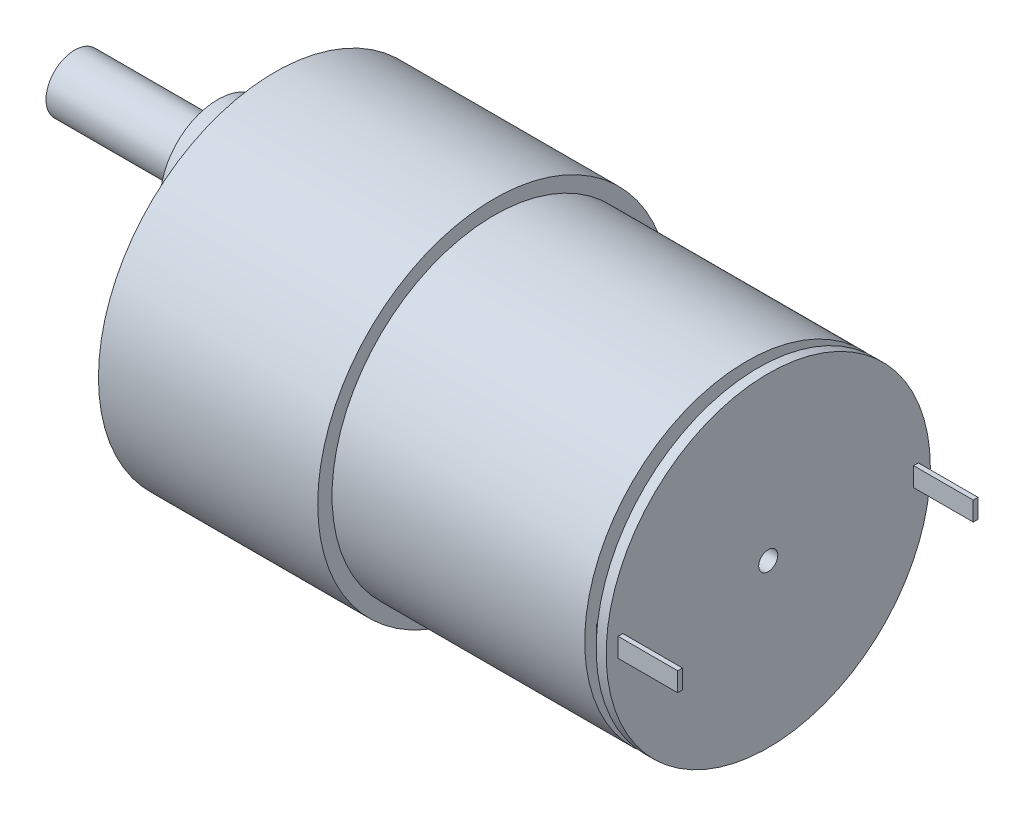
from build123d import *

# Parameters (mm, degrees)
SKETCH1_R                      = 17
BOSS_EXTRUDE1_DEPTH            = 1.05
SKETCH2_W                      = 0.5
SKETCH2_H                      = 2
POLES_DEPTH                    = 1.2
POLES_DEPTH_BACK               = 7.3
SKETCH3_R                      = 1.5
BOSS_EXTRUDE3_DEPTH            = 1.2
SKETCH5_R                      = 17
BOSS_EXTRUDE5_DEPTH            = 26.5
SKETCH6_R                      = 18.5
REDUCTUR_DEPTH                 = 21.5
SKETCH35_R                     = 18.5
ENDPLATE_DEPTH                 = 1.5
SKETCH36_R                     = 6
BOSS_EXTRUDE25_DEPTH           = 6
F_3_1_3_1_DIAMETER_HOLE1_D     = 6
F_3_1_3_1_DIAMETER_HOLE1_DEPTH = 2.2
F_2_0_2_DIAMETER_HOLE1_D       = 2
F_2_0_2_DIAMETER_HOLE1_DEPTH   = 2.25
F_3_0MM_1_D                    = 3
F_3_0MM_1_DEPTH                = 7.5
F_3_0MM_1_TIP                  = 0.901290929
SKETCH_1_R                     = 3
EXTRUDE_1_DEPTH                = 21


with BuildPart() as part:
    # Sketch1 → Boss-Extrude1 (new body)
    with BuildSketch(Plane(origin=(41.25, 0, 0), x_dir=(0, 0, -1), z_dir=(1, 0, 0))):
        Circle(SKETCH1_R)
    extrude(amount=-BOSS_EXTRUDE1_DEPTH)

    # Sketch2 → Poles (add, two sides)
    with BuildSketch(Plane.ZY.offset(-40.2)) as poles_sk:
        with Locations((15.5, 0)):
            Rectangle(SKETCH2_W, SKETCH2_H)
        with Locations((-15.5, 0)):
            Rectangle(SKETCH2_W, SKETCH2_H)
    extrude(amount=POLES_DEPTH)
    extrude(poles_sk.sketch, amount=-POLES_DEPTH_BACK)

    # Sketch3 → Boss-Extrude3 (add)
    with BuildSketch(Plane.ZY.offset(-40.2)):
        Circle(SKETCH3_R)
    extrude(amount=BOSS_EXTRUDE3_DEPTH)

    # Sketch5 → Boss-Extrude5 (add)
    with BuildSketch(Plane(origin=(39, 0, 0), x_dir=(0, 0, -1), z_dir=(1, 0, 0))):
        Circle(SKETCH5_R)
    extrude(amount=-BOSS_EXTRUDE5_DEPTH)

    # Sketch6 → Reductur (add)
    with BuildSketch(Plane(origin=(12.5, 0, 0), x_dir=(0, 0, -1), z_dir=(1, 0, 0))):
        Circle(SKETCH6_R)
    extrude(amount=-REDUCTUR_DEPTH)

    # Sketch35 → Endplate (add)
    with BuildSketch(Plane.ZY.offset(9)):
        Circle(SKETCH35_R)
    extrude(amount=ENDPLATE_DEPTH)

    # Sketch36 → Boss-Extrude25 (add)
    with BuildSketch(Plane.ZY.offset(10.5)):
        with Locations((0, 7)):
            Circle(SKETCH36_R)
    extrude(amount=BOSS_EXTRUDE25_DEPTH)

    # Ø3.1 (3.1) Diameter Hole1
    with Locations(Plane.ZY.offset(16.5)):
        with Locations((0, 7)):
            Hole(F_3_1_3_1_DIAMETER_HOLE1_D / 2, depth=F_3_1_3_1_DIAMETER_HOLE1_DEPTH)

    # Ø2.0 (2) Diameter Hole1
    with Locations(Plane(origin=(41.25, 0, 0), x_dir=(0, 0, -1), z_dir=(1, 0, 0))):
        with Locations((0, 0)):
            Hole(F_2_0_2_DIAMETER_HOLE1_D / 2, depth=F_2_0_2_DIAMETER_HOLE1_DEPTH)

    # Ø3.0mm 定位孔1
    with Locations(Plane(origin=(-10.5, 0, -15.5), x_dir=(0, 0, -1), z_dir=(-1, 0, 0))):
        with Locations((0, 0), (-7.75, -13.423393759), (-23.50507477, -13.272858695), (-31, 0), (-23.25, 13.423393759), (-7.75, 13.423393759)):
            Hole(F_3_0MM_1_D / 2, depth=F_3_0MM_1_DEPTH)
            with Locations((0, 0, -(F_3_0MM_1_DEPTH + F_3_0MM_1_TIP / 2))):  # 118° drill point
                Cone(0, F_3_0MM_1_D / 2, F_3_0MM_1_TIP, mode=Mode.SUBTRACT)

    # 草圖1 → 填料-伸長1 (add)
    with BuildSketch(Plane.ZY.offset(10.5)):
        with Locations((0, 7)):
            Circle(SKETCH_1_R)
    extrude(amount=EXTRUDE_1_DEPTH)


solid = part.part
